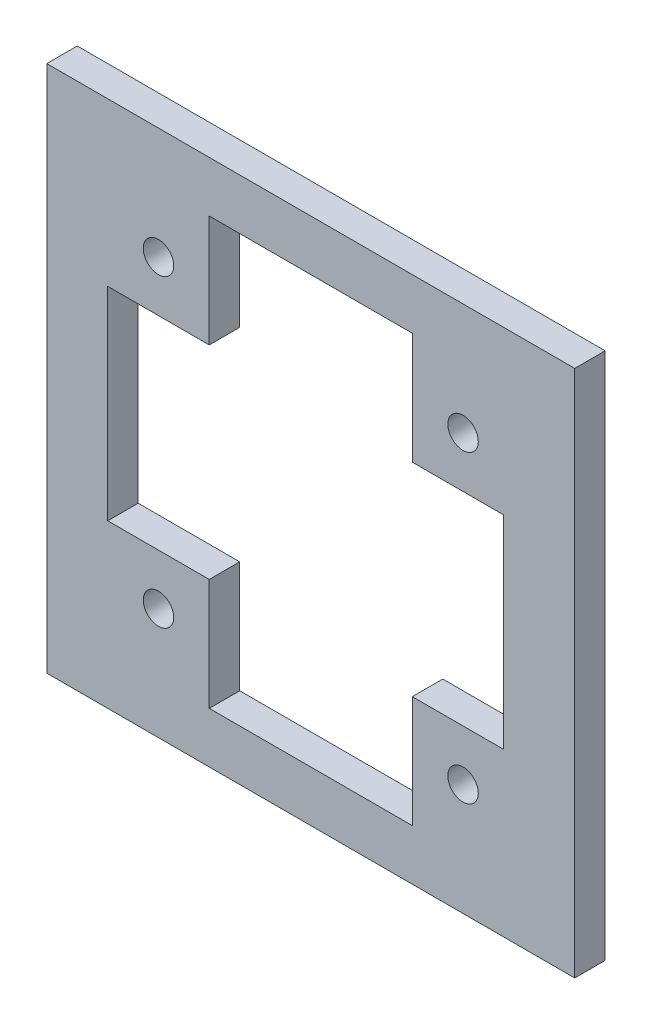
from build123d import *

# Parameters (mm, degrees)
MODEL_W                 = 52
MODEL_H                 = 52
MODEL_R                 = 1.5
SALIENTE_EXTRUIR1_DEPTH = 3


with BuildPart() as part:
    # Model → Saliente-Extruir1 (new body)
    with BuildSketch(Plane.XY):
        with Locations((26, 26)):
            Rectangle(MODEL_W, MODEL_H)
        with Locations((41, 41)):
            Circle(MODEL_R, mode=Mode.SUBTRACT)
        with Locations((41, 11)):
            Circle(MODEL_R, mode=Mode.SUBTRACT)
        with Locations((11, 11)):
            Circle(MODEL_R, mode=Mode.SUBTRACT)
        with Locations((11, 41)):
            Circle(MODEL_R, mode=Mode.SUBTRACT)
        Polygon((36, 16), (45, 16), (45, 36), (36, 36), (36, 47), (16, 47), (16, 36), (6, 36), (6, 16), (16, 16), (16, 5), (36, 5), align=None, mode=Mode.SUBTRACT)
    extrude(amount=SALIENTE_EXTRUIR1_DEPTH)


solid = part.part
